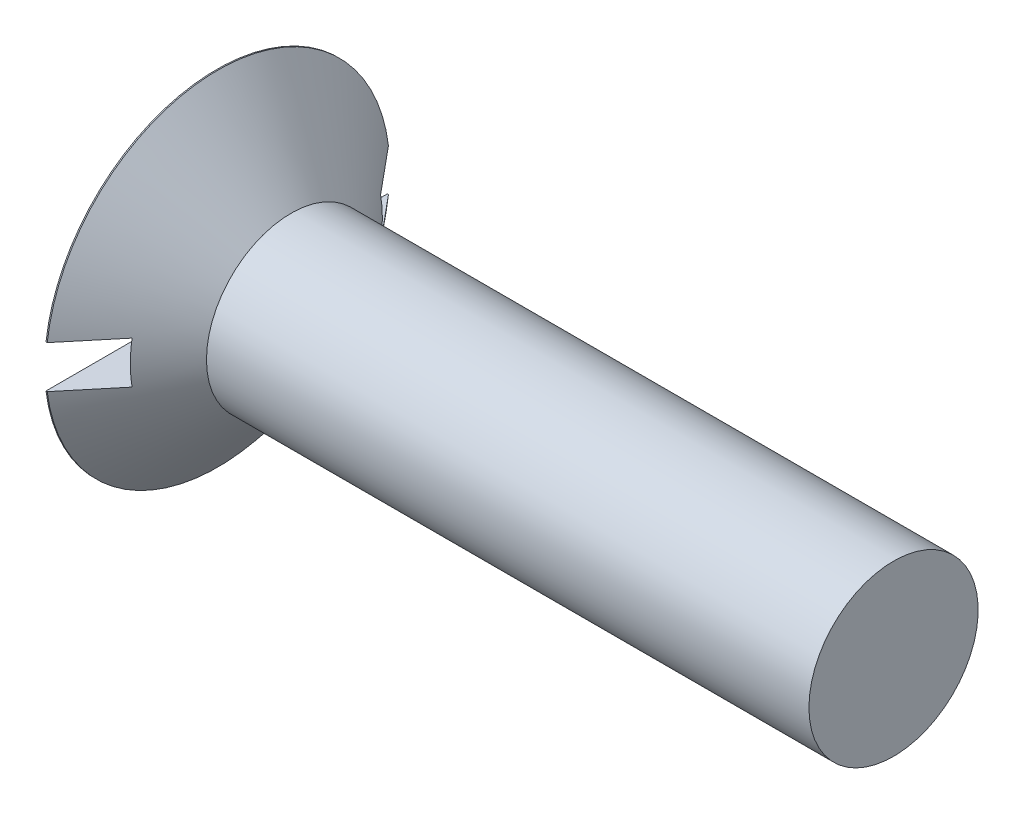
from build123d import *

# Parameters (mm, degrees)
SKETCH2_W         = 19.3548
SKETCH2_H         = 2.3876
SLOT_DEPTH        = 2.2352
SKETCH3_W         = 2.1844
SKETCH3_H         = 13.2842
SKETCH4_W         = 1.0922
SKETCH4_H         = 1.0922
CIRPATTERN1_COUNT = 2
CIRPATTERN1_ANGLE = 90


with BuildPart() as part:
    # BodySke → Base-Revolve (revolve)
    with BuildSketch(Plane.XY, mode=Mode.PRIVATE) as base_revolve_sk:
        Polygon((0, 0), (0, 9.6774), (0.066909223, 9.6774), (4.191, 4.7625), (38.1, 4.7625), (38.1, 0), align=None)
    revolve(base_revolve_sk.sketch.rotate(Axis((-6.35, 0, 0), (1, 0, 0)), 90), axis=Axis((-6.35, 0, 0), (1, 0, 0)))  # turned: the seam where the file's is

    # Sketch2 → Slot (cut)
    with BuildSketch(Plane.ZY):
        Rectangle(SKETCH2_W, SKETCH2_H)
    extrude(amount=-SLOT_DEPTH, mode=Mode.SUBTRACT)

    # Sketch3 → Cross section 0
    with BuildSketch(Plane.ZY):
        Rectangle(SKETCH3_W, SKETCH3_H)
    # Sketch4 → Cross section 1
    with BuildSketch(Plane.ZY.offset(-7.9756)):
        Rectangle(SKETCH4_W, SKETCH4_H)
    cross = loft(mode=Mode.SUBTRACT)

    # CirPattern1: Cross ×2 about axis
    cirpattern1_axis = Axis((0, 0, 0), (1, 0, 0))
    for i in range(1, CIRPATTERN1_COUNT):
        add(cross.rotate(cirpattern1_axis, i * CIRPATTERN1_ANGLE / (CIRPATTERN1_COUNT - 1)), mode=Mode.SUBTRACT)


solid = part.part
